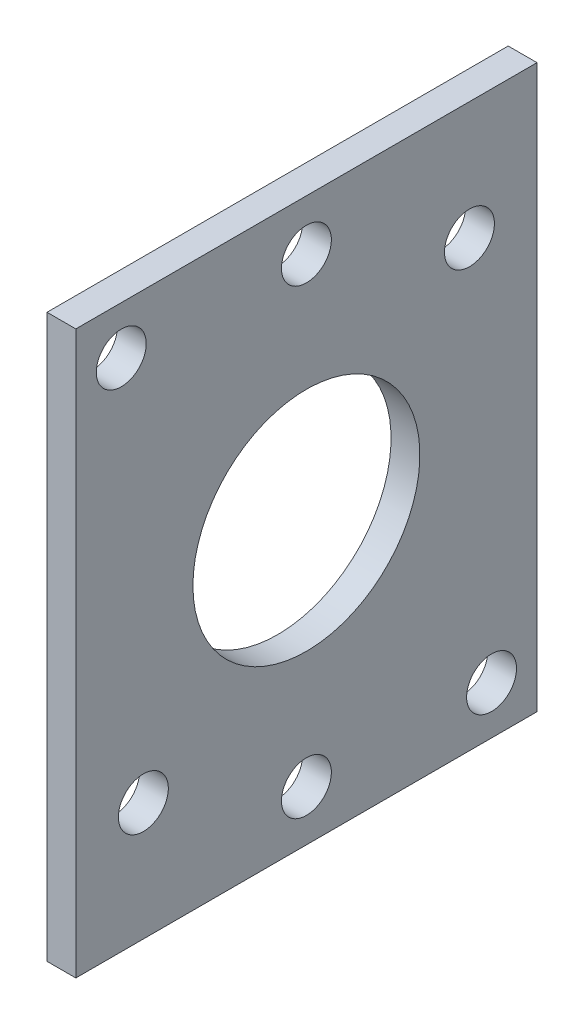
from build123d import *

# Parameters (mm, degrees)
SKETCH1_W           = 50.8
SKETCH1_H           = 61.92
BOSS_EXTRUDE2_DEPTH = 3.175
SKETCH2_R           = 12.5
SKETCH2_R_2         = 2.75
CUT_EXTRUDE1_DEPTH  = 4.175


with BuildPart() as part:
    # Sketch1 → Boss-Extrude2 (new body)
    with BuildSketch(Plane(origin=(0, 0, 0), x_dir=(0, 0, -1), z_dir=(1, 0, 0))):
        with Locations((25.4, 30.96)):
            Rectangle(SKETCH1_W, SKETCH1_H)
    extrude(amount=BOSS_EXTRUDE2_DEPTH)

    # Sketch2 → Cut-Extrude1 (cut, through all)
    with BuildSketch(Plane.ZY):
        with Locations((-25.399655405, 30.96)):
            Circle(SKETCH2_R)
        with Locations((-43.35992398, 48.920755906)):
            Circle(SKETCH2_R_2)
        with Locations((-25.399655405, 56.36)):
            Circle(SKETCH2_R_2)
        with Locations((-5.004504526, 56.648087135)):
            Circle(SKETCH2_R_2)
        with Locations((-25.399655405, 5.560695)):
            Circle(SKETCH2_R_2)
        with Locations((-45.795509398, 5.272471121)):
            Circle(SKETCH2_R_2)
        with Locations((-7.439487758, 13.000182758)):
            Circle(SKETCH2_R_2)
    extrude(amount=-CUT_EXTRUDE1_DEPTH, mode=Mode.SUBTRACT)


solid = part.part
